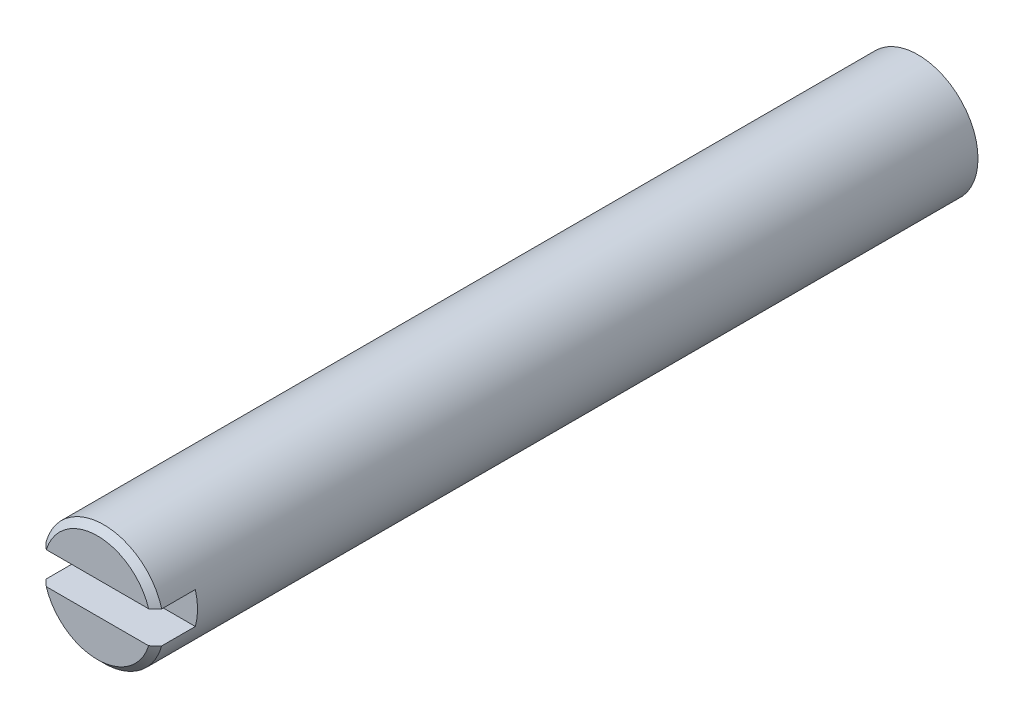
from build123d import *

# Parameters (mm, degrees)
SKETCH1_R           = 4.7625
BOSS_EXTRUDE1_DEPTH = 65.1002
SKETCH2_W           = 9.525
SKETCH2_H           = 2.54
CUT_EXTRUDE1_DEPTH  = 3.175
CHAMFER1_SIZE       = 0.508


with BuildPart() as part:
    # Sketch1 → Boss-Extrude1 (new body)
    with BuildSketch(Plane.XY):
        Circle(SKETCH1_R)
    extrude(amount=BOSS_EXTRUDE1_DEPTH)

    # Sketch2 → Cut-Extrude1 (cut)
    with BuildSketch(Plane.XY.offset(65.1002)):
        Rectangle(SKETCH2_W, SKETCH2_H)
    extrude(amount=-CUT_EXTRUDE1_DEPTH, mode=Mode.SUBTRACT)

    # Chamfer1
    chamfer1_edges = [part.edges().sort_by_distance(p)[0] for p in [
        (0, 4.7625, 65.1002),
        (0, -4.7625, 65.1002),
    ]]
    chamfer(chamfer1_edges, length=CHAMFER1_SIZE)


solid = part.part
